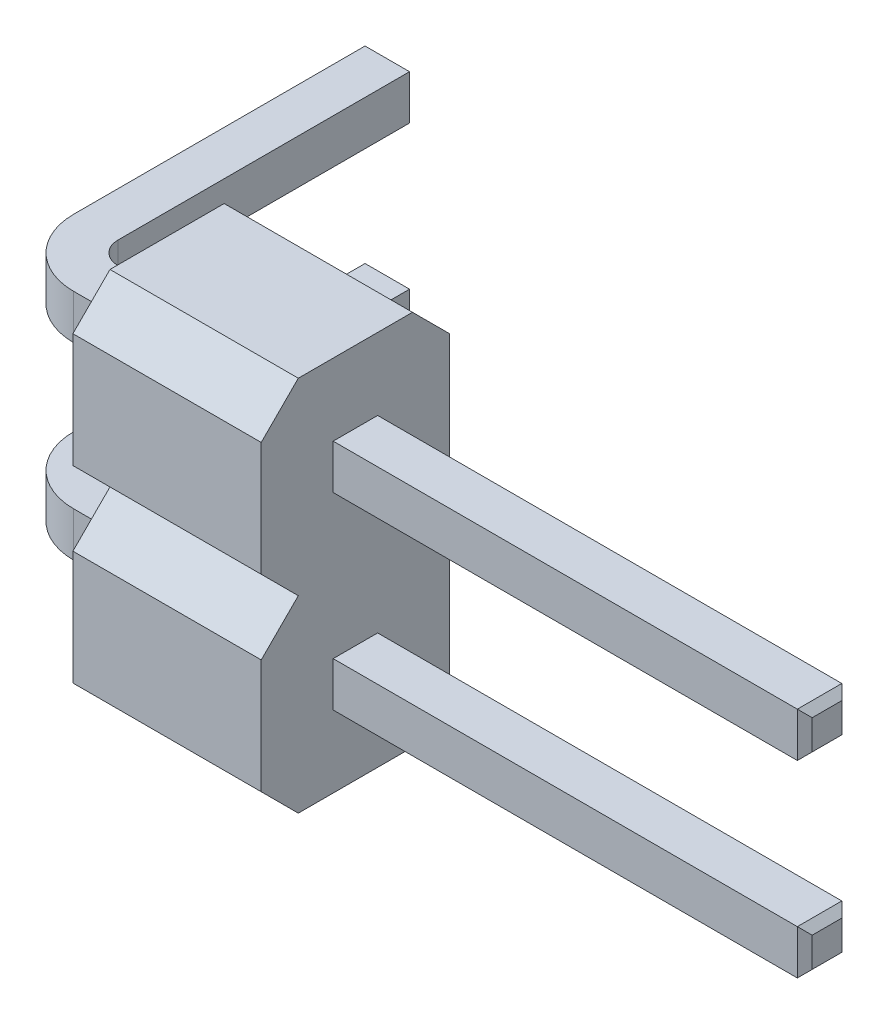
from build123d import *

# Parameters (mm, degrees)
PLASTIC_DEPTH   = 2.54
CONTACT_DEPTH   = 0.3
CHAMFER1_SIZE   = 0.1
LPATTERN1_COUNT = 2
LPATTERN1_PITCH = 2.54


with BuildPart() as part:
    # Sketch1 → Plastic (new body)
    with BuildSketch(Plane(origin=(0, 0, 0), x_dir=(0, 0, -1), z_dir=(1, 0, 0))):
        Polygon((-2.04, 1.27), (-0.5, 1.27), (0, 0.77), (0, -0.77), (-0.5, -1.27), (-2.04, -1.27), (-2.54, -0.77), (-2.54, 0.77), align=None)
    extrude(amount=PLASTIC_DEPTH)

    # Sketch2 → Contact (add, symmetric)
    with BuildSketch(Plane(origin=(0, 0, 0), x_dir=(1, 0, 0), z_dir=(0, 1, 0))):
        with BuildLine():
            Line((-1.86, 3.36), (-1.86, -0.67))
            ThreePointArc((-1.86, -0.67), (-1.596396103, -1.306396103), (-0.96, -1.57))
            Line((-0.96, -1.57), (8.9, -1.57))
            Line((8.9, -1.57), (8.9, -0.97))
            Line((8.9, -0.97), (-0.96, -0.97))
            ThreePointArc((-0.96, -0.97), (-1.172132034, -0.882132034), (-1.26, -0.67))
            Line((-1.26, -0.67), (-1.26, 3.36))
            Line((-1.26, 3.36), (-1.86, 3.36))
        make_face()
    extrude(amount=CONTACT_DEPTH, both=True)

    # Chamfer1
    chamfer1_edges = [part.edges().sort_by_distance(p)[0] for p in [
        (8.9, 0.3, 1.27),
        (8.9, 0, 1.57),
        (8.9, -0.3, 1.27),
        (8.9, 0, 0.97),
        (-1.56, 0.3, -3.36),
        (-1.26, 0, -3.36),
        (-1.86, 0, -3.36),
        (-1.56, -0.3, -3.36),
    ]]
    chamfer(chamfer1_edges, length=CHAMFER1_SIZE)

    # LPattern1: part ×2


with BuildPart() as part_1:
    add(part.part)
    with Locations(*[(0, i * LPATTERN1_PITCH, 0) for i in range(1, LPATTERN1_COUNT)]):
        add(part.part)


solid = part_1.part
